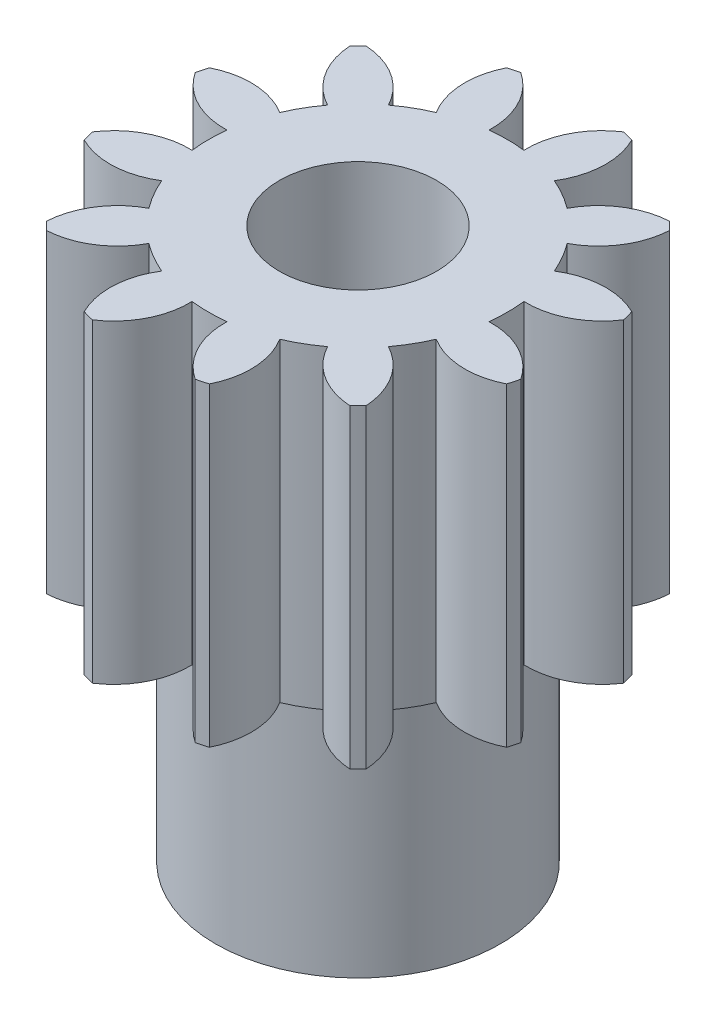
from build123d import *

# Parameters (mm, degrees)
SKETCH1_R           = 17
BOSS_EXTRUDE1_DEPTH = 20
SKETCH2_R           = 17
CUT_EXTRUDE1_DEPTH  = 15
SKETCH4_R           = 17
CUT_EXTRUDE2_DEPTH  = 5
SKETCH5_R           = 9.05
BOSS_EXTRUDE2_DEPTH = 15
SKETCH6_R           = 5
CUT_EXTRUDE3_DEPTH  = 35


with BuildPart() as part:
    # Sketch1 → Boss-Extrude1 (new body)
    with BuildSketch(Plane(origin=(0, 0, 0), x_dir=(1, 0, 0), z_dir=(0, 1, 0))):
        Circle(SKETCH1_R)
    extrude(amount=BOSS_EXTRUDE1_DEPTH)

    # Sketch2 → Cut-Extrude1 (cut)
    with BuildSketch(Plane(origin=(-13.818246137, 15, -17.496579046), x_dir=(1, 0, 0), z_dir=(0, 1, 0))):
        with Locations((13.818246137, -17.496579046)):
            Circle(SKETCH2_R)
        with BuildLine():
            ThreePointArc((19.498036508, -25.110446812), (21.14436633, -26.898819817), (23.455733413, -27.651323701))
            ThreePointArc((23.455733413, -27.651323701), (23.717741074, -27.396073983), (23.972990792, -27.134066322))
            ThreePointArc((23.972990792, -27.134066322), (23.220486908, -24.822699239), (21.432113903, -23.176369417))
            ThreePointArc((21.432113903, -23.176369417), (22.044621448, -22.246079046), (22.544022769, -21.250486767))
            ThreePointArc((22.544022769, -21.250486767), (24.86397272, -21.97609831), (27.241927274, -21.472102249))
            ThreePointArc((27.241927274, -21.472102249), (27.341207705, -21.120045678), (27.431256615, -20.765515528))
            ThreePointArc((27.431256615, -20.765515528), (25.623885593, -19.140064859), (23.251944228, -18.608487912))
            ThreePointArc((23.251944228, -18.608487912), (23.317246137, -17.496579046), (23.251944228, -16.38467018))
            ThreePointArc((23.251944228, -16.38467018), (25.623885593, -15.853093234), (27.431256615, -14.227642564))
            ThreePointArc((27.431256615, -14.227642564), (27.341207705, -13.873112415), (27.241927274, -13.521055844))
            ThreePointArc((27.241927274, -13.521055844), (24.86397272, -13.017059783), (22.544022769, -13.742671325))
            ThreePointArc((22.544022769, -13.742671325), (22.044621448, -12.747079046), (21.432113903, -11.816788676))
            ThreePointArc((21.432113903, -11.816788676), (23.220486908, -10.170458854), (23.972990792, -7.85909177))
            ThreePointArc((23.972990792, -7.85909177), (23.717741074, -7.59708411), (23.455733413, -7.341834391))
            ThreePointArc((23.455733413, -7.341834391), (21.14436633, -8.094338276), (19.498036508, -9.882711281))
            ThreePointArc((19.498036508, -9.882711281), (18.567746137, -9.270203736), (17.572153858, -8.770802415))
            ThreePointArc((17.572153858, -8.770802415), (18.297765401, -6.450852463), (17.79376934, -4.072897909))
            ThreePointArc((17.79376934, -4.072897909), (17.441712769, -3.973617478), (17.087182619, -3.883568568))
            ThreePointArc((17.087182619, -3.883568568), (15.46173195, -5.69093959), (14.930155003, -8.062880955))
            ThreePointArc((14.930155003, -8.062880955), (13.818246137, -7.997579046), (12.706337271, -8.062880955))
            ThreePointArc((12.706337271, -8.062880955), (12.174760325, -5.69093959), (10.549309655, -3.883568568))
            ThreePointArc((10.549309655, -3.883568568), (10.194779506, -3.973617478), (9.842722935, -4.072897909))
            ThreePointArc((9.842722935, -4.072897909), (9.338726874, -6.450852463), (10.064338416, -8.770802415))
            ThreePointArc((10.064338416, -8.770802415), (9.068746137, -9.270203736), (8.138455767, -9.882711281))
            ThreePointArc((8.138455767, -9.882711281), (6.492125945, -8.094338276), (4.180758862, -7.341834391))
            ThreePointArc((4.180758862, -7.341834391), (3.918751201, -7.59708411), (3.663501482, -7.85909177))
            ThreePointArc((3.663501482, -7.85909177), (4.416005367, -10.170458854), (6.204378372, -11.816788676))
            ThreePointArc((6.204378372, -11.816788676), (5.591870827, -12.747079046), (5.092469506, -13.742671325))
            ThreePointArc((5.092469506, -13.742671325), (2.772519554, -13.017059783), (0.394565, -13.521055844))
            ThreePointArc((0.394565, -13.521055844), (0.295284569, -13.873112415), (0.205235659, -14.227642564))
            ThreePointArc((0.205235659, -14.227642564), (2.012606681, -15.853093234), (4.384548046, -16.38467018))
            ThreePointArc((4.384548046, -16.38467018), (4.319246137, -17.496579046), (4.384548046, -18.608487912))
            ThreePointArc((4.384548046, -18.608487912), (2.012606681, -19.140064859), (0.205235659, -20.765515528))
            ThreePointArc((0.205235659, -20.765515528), (0.295284569, -21.120045678), (0.394565, -21.472102249))
            ThreePointArc((0.394565, -21.472102249), (2.772519554, -21.97609831), (5.092469506, -21.250486767))
            ThreePointArc((5.092469506, -21.250486767), (5.591870827, -22.246079046), (6.204378372, -23.176369417))
            ThreePointArc((6.204378372, -23.176369417), (4.416005367, -24.822699239), (3.663501482, -27.134066322))
            ThreePointArc((3.663501482, -27.134066322), (3.918751201, -27.396073983), (4.180758862, -27.651323701))
            ThreePointArc((4.180758862, -27.651323701), (6.492125945, -26.898819817), (8.138455767, -25.110446812))
            ThreePointArc((8.138455767, -25.110446812), (9.068746137, -25.722954357), (10.064338416, -26.222355678))
            ThreePointArc((10.064338416, -26.222355678), (9.338726874, -28.542305629), (9.842722935, -30.920260183))
            ThreePointArc((9.842722935, -30.920260183), (10.194779506, -31.019540614), (10.549309655, -31.109589524))
            ThreePointArc((10.549309655, -31.109589524), (12.174760325, -29.302218502), (12.706337271, -26.930277137))
            ThreePointArc((12.706337271, -26.930277137), (13.818246137, -26.995579046), (14.930155003, -26.930277137))
            ThreePointArc((14.930155003, -26.930277137), (15.46173195, -29.302218502), (17.087182619, -31.109589524))
            ThreePointArc((17.087182619, -31.109589524), (17.441712769, -31.019540614), (17.79376934, -30.920260183))
            ThreePointArc((17.79376934, -30.920260183), (18.297765401, -28.542305629), (17.572153858, -26.222355678))
            ThreePointArc((17.572153858, -26.222355678), (18.567746137, -25.722954357), (19.498036508, -25.110446812))
        make_face(mode=Mode.SUBTRACT)
    extrude(amount=-CUT_EXTRUDE1_DEPTH, mode=Mode.SUBTRACT)

    # Sketch4 → Cut-Extrude2 (cut)
    with BuildSketch(Plane.XZ.offset(-15)):
        Circle(SKETCH4_R)
        with BuildLine():
            ThreePointArc((5.67979037, 7.613867765), (4.7495, 8.226375311), (3.753907721, 8.725776632))
            ThreePointArc((3.753907721, 8.725776632), (4.479519264, 11.045726583), (3.975523202, 13.423681137))
            ThreePointArc((3.975523202, 13.423681137), (3.623466631, 13.522961568), (3.268936482, 13.613010478))
            ThreePointArc((3.268936482, 13.613010478), (1.643485813, 11.805639456), (1.111908866, 9.433698091))
            ThreePointArc((1.111908866, 9.433698091), (0, 9.499), (-1.111908866, 9.433698091))
            ThreePointArc((-1.111908866, 9.433698091), (-1.643485813, 11.805639456), (-3.268936482, 13.613010478))
            ThreePointArc((-3.268936482, 13.613010478), (-3.623466631, 13.522961568), (-3.975523202, 13.423681137))
            ThreePointArc((-3.975523202, 13.423681137), (-4.479519264, 11.045726583), (-3.753907721, 8.725776632))
            ThreePointArc((-3.753907721, 8.725776632), (-4.7495, 8.226375311), (-5.67979037, 7.613867765))
            ThreePointArc((-5.67979037, 7.613867765), (-7.326120193, 9.402240771), (-9.637487276, 10.154744655))
            ThreePointArc((-9.637487276, 10.154744655), (-9.899494937, 9.899494937), (-10.154744655, 9.637487276))
            ThreePointArc((-10.154744655, 9.637487276), (-9.402240771, 7.326120193), (-7.613867765, 5.67979037))
            ThreePointArc((-7.613867765, 5.67979037), (-8.226375311, 4.7495), (-8.725776632, 3.753907721))
            ThreePointArc((-8.725776632, 3.753907721), (-11.045726583, 4.479519264), (-13.423681137, 3.975523202))
            ThreePointArc((-13.423681137, 3.975523202), (-13.522961568, 3.623466631), (-13.613010478, 3.268936482))
            ThreePointArc((-13.613010478, 3.268936482), (-11.805639456, 1.643485813), (-9.433698091, 1.111908866))
            ThreePointArc((-9.433698091, 1.111908866), (-9.499, 0), (-9.433698091, -1.111908866))
            ThreePointArc((-9.433698091, -1.111908866), (-11.805639456, -1.643485813), (-13.613010478, -3.268936482))
            ThreePointArc((-13.613010478, -3.268936482), (-13.522961568, -3.623466631), (-13.423681137, -3.975523202))
            ThreePointArc((-13.423681137, -3.975523202), (-11.045726583, -4.479519264), (-8.725776632, -3.753907721))
            ThreePointArc((-8.725776632, -3.753907721), (-8.226375311, -4.7495), (-7.613867765, -5.67979037))
            ThreePointArc((-7.613867765, -5.67979037), (-9.402240771, -7.326120193), (-10.154744655, -9.637487276))
            ThreePointArc((-10.154744655, -9.637487276), (-9.899494937, -9.899494937), (-9.637487276, -10.154744655))
            ThreePointArc((-9.637487276, -10.154744655), (-7.326120193, -9.402240771), (-5.67979037, -7.613867765))
            ThreePointArc((-5.67979037, -7.613867765), (-4.7495, -8.226375311), (-3.753907721, -8.725776632))
            ThreePointArc((-3.753907721, -8.725776632), (-4.479519264, -11.045726583), (-3.975523202, -13.423681137))
            ThreePointArc((-3.975523202, -13.423681137), (-3.623466631, -13.522961568), (-3.268936482, -13.613010478))
            ThreePointArc((-3.268936482, -13.613010478), (-1.643485813, -11.805639456), (-1.111908866, -9.433698091))
            ThreePointArc((-1.111908866, -9.433698091), (0, -9.499), (1.111908866, -9.433698091))
            ThreePointArc((1.111908866, -9.433698091), (1.643485813, -11.805639456), (3.268936482, -13.613010478))
            ThreePointArc((3.268936482, -13.613010478), (3.623466631, -13.522961568), (3.975523202, -13.423681137))
            ThreePointArc((3.975523202, -13.423681137), (4.479519264, -11.045726583), (3.753907721, -8.725776632))
            ThreePointArc((3.753907721, -8.725776632), (4.7495, -8.226375311), (5.67979037, -7.613867765))
            ThreePointArc((5.67979037, -7.613867765), (7.326120193, -9.402240771), (9.637487276, -10.154744655))
            ThreePointArc((9.637487276, -10.154744655), (9.899494937, -9.899494937), (10.154744655, -9.637487276))
            ThreePointArc((10.154744655, -9.637487276), (9.402240771, -7.326120193), (7.613867765, -5.67979037))
            ThreePointArc((7.613867765, -5.67979037), (8.226375311, -4.7495), (8.725776632, -3.753907721))
            ThreePointArc((8.725776632, -3.753907721), (11.045726583, -4.479519264), (13.423681137, -3.975523202))
            ThreePointArc((13.423681137, -3.975523202), (13.522961568, -3.623466631), (13.613010478, -3.268936482))
            ThreePointArc((13.613010478, -3.268936482), (11.805639456, -1.643485813), (9.433698091, -1.111908866))
            ThreePointArc((9.433698091, -1.111908866), (9.499, 0), (9.433698091, 1.111908866))
            ThreePointArc((9.433698091, 1.111908866), (11.805639456, 1.643485813), (13.613010478, 3.268936482))
            ThreePointArc((13.613010478, 3.268936482), (13.522961568, 3.623466631), (13.423681137, 3.975523202))
            ThreePointArc((13.423681137, 3.975523202), (11.045726583, 4.479519264), (8.725776632, 3.753907721))
            ThreePointArc((8.725776632, 3.753907721), (8.226375311, 4.7495), (7.613867765, 5.67979037))
            ThreePointArc((7.613867765, 5.67979037), (9.402240771, 7.326120193), (10.154744655, 9.637487276))
            ThreePointArc((10.154744655, 9.637487276), (9.899494937, 9.899494937), (9.637487276, 10.154744655))
            ThreePointArc((9.637487276, 10.154744655), (7.326120193, 9.402240771), (5.67979037, 7.613867765))
        make_face(mode=Mode.SUBTRACT)
    extrude(amount=-CUT_EXTRUDE2_DEPTH, mode=Mode.SUBTRACT)

    # Sketch5 → Boss-Extrude2 (add)
    with BuildSketch(Plane.XZ):
        Circle(SKETCH5_R)
    extrude(amount=BOSS_EXTRUDE2_DEPTH)

    # Sketch6 → Cut-Extrude3 (cut)
    with BuildSketch(Plane.XZ.offset(15)):
        Circle(SKETCH6_R)
    extrude(amount=-CUT_EXTRUDE3_DEPTH, mode=Mode.SUBTRACT)


solid = part.part
